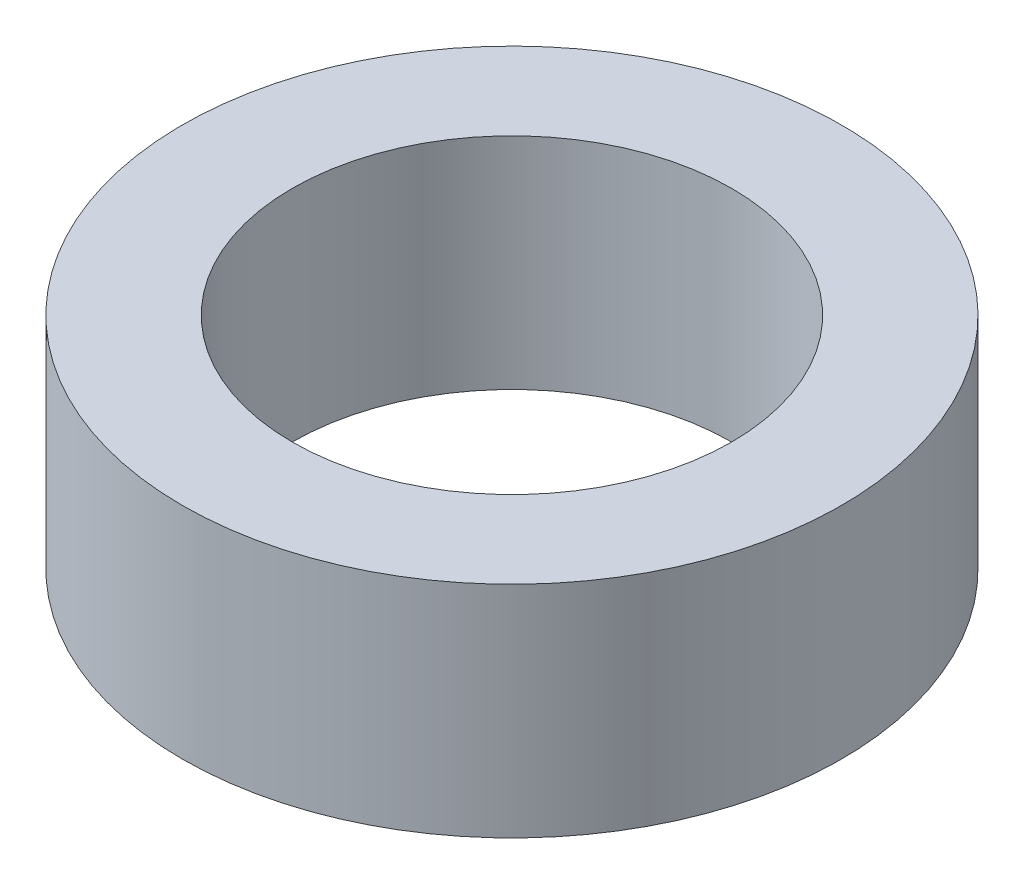
from build123d import *

# Parameters (mm, degrees)
SKETCH1_R           = 4.7625
SKETCH1_R_2         = 3.175
BOSS_EXTRUDE1_DEPTH = 3.175


with BuildPart() as part:
    # Sketch1 → Boss-Extrude1 (new body)
    with BuildSketch(Plane(origin=(0, 0, 0), x_dir=(1, 0, 0), z_dir=(0, 1, 0))):
        Circle(SKETCH1_R)
        Circle(SKETCH1_R_2, mode=Mode.SUBTRACT)
    extrude(amount=BOSS_EXTRUDE1_DEPTH)


solid = part.part
